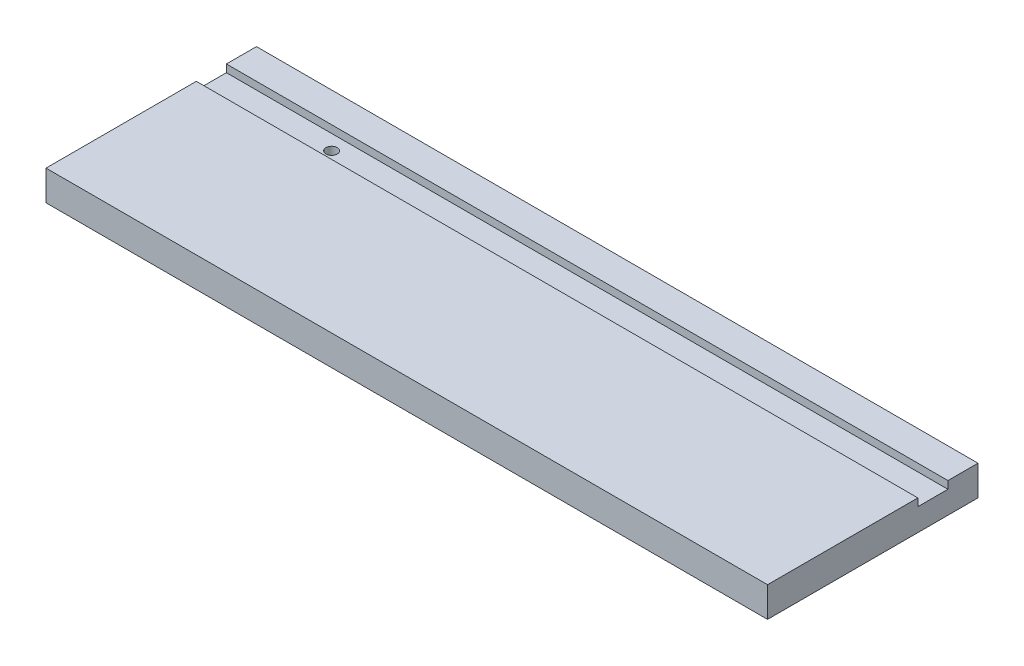
from build123d import *

# Parameters (mm, degrees)
SKETCH1_W           = 152.4
SKETCH1_H           = 44.45
BOSS_EXTRUDE1_DEPTH = 6.35
SKETCH2_W           = 146.05
SKETCH2_H           = 6.35
CUT_EXTRUDE1_DEPTH  = 1.6002
SKETCH3_R           = 1.18745
CUT_EXTRUDE2_DEPTH  = 5.7498
SKETCH4_W           = 6.35
SKETCH4_H           = 6.35
CUT_EXTRUDE3_DEPTH  = 1.6002


with BuildPart() as part:
    # Sketch1 → Boss-Extrude1 (new body)
    with BuildSketch(Plane(origin=(0, 0, 0), x_dir=(1, 0, 0), z_dir=(0, 1, 0))):
        with Locations((76.2, 22.225)):
            Rectangle(SKETCH1_W, SKETCH1_H)
    extrude(amount=BOSS_EXTRUDE1_DEPTH)

    # Sketch2 → Cut-Extrude1 (cut)
    with BuildSketch(Plane(origin=(0, 6.35, 0), x_dir=(1, 0, 0), z_dir=(0, 1, 0))):
        with Locations((73.025, 34.925)):
            Rectangle(SKETCH2_W, SKETCH2_H)
    extrude(amount=-CUT_EXTRUDE1_DEPTH, mode=Mode.SUBTRACT)

    # Sketch3 → Cut-Extrude2 (cut, through all)
    with BuildSketch(Plane(origin=(0, 4.7498, 0), x_dir=(1, 0, 0), z_dir=(0, 1, 0))):
        with Locations((25.4, 34.925)):
            Circle(SKETCH3_R)
    extrude(amount=-CUT_EXTRUDE2_DEPTH, mode=Mode.SUBTRACT)

    # Sketch4 → Cut-Extrude3 (cut)
    with BuildSketch(Plane(origin=(0, 6.35, 0), x_dir=(1, 0, 0), z_dir=(0, 1, 0))):
        with Locations((149.225, 34.925)):
            Rectangle(SKETCH4_W, SKETCH4_H)
    extrude(amount=-CUT_EXTRUDE3_DEPTH, mode=Mode.SUBTRACT)


solid = part.part
